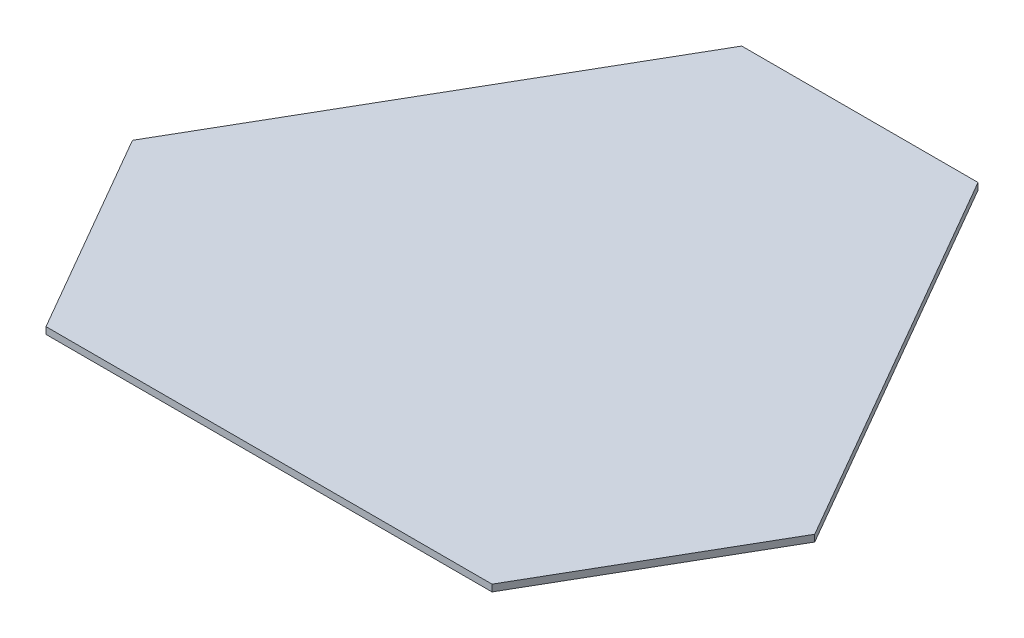
from build123d import *

# Parameters (mm, degrees)
BOSS_EXTRUDE1_DEPTH = 3


with BuildPart() as part:
    # Sketch3 → Boss-Extrude1 (new body)
    with BuildSketch(Plane(origin=(0, 0, 0), x_dir=(1, 0, 0), z_dir=(0, 1, 0))):
        Polygon((-151.171989963, -70.138837487), (-52.343979926, 101.036297108), (52.343979926, 101.036297108), (151.171989963, -70.138837487), (98.828010037, -160.801270189), (-98.828010037, -160.801270189), align=None)
    extrude(amount=BOSS_EXTRUDE1_DEPTH)


solid = part.part
